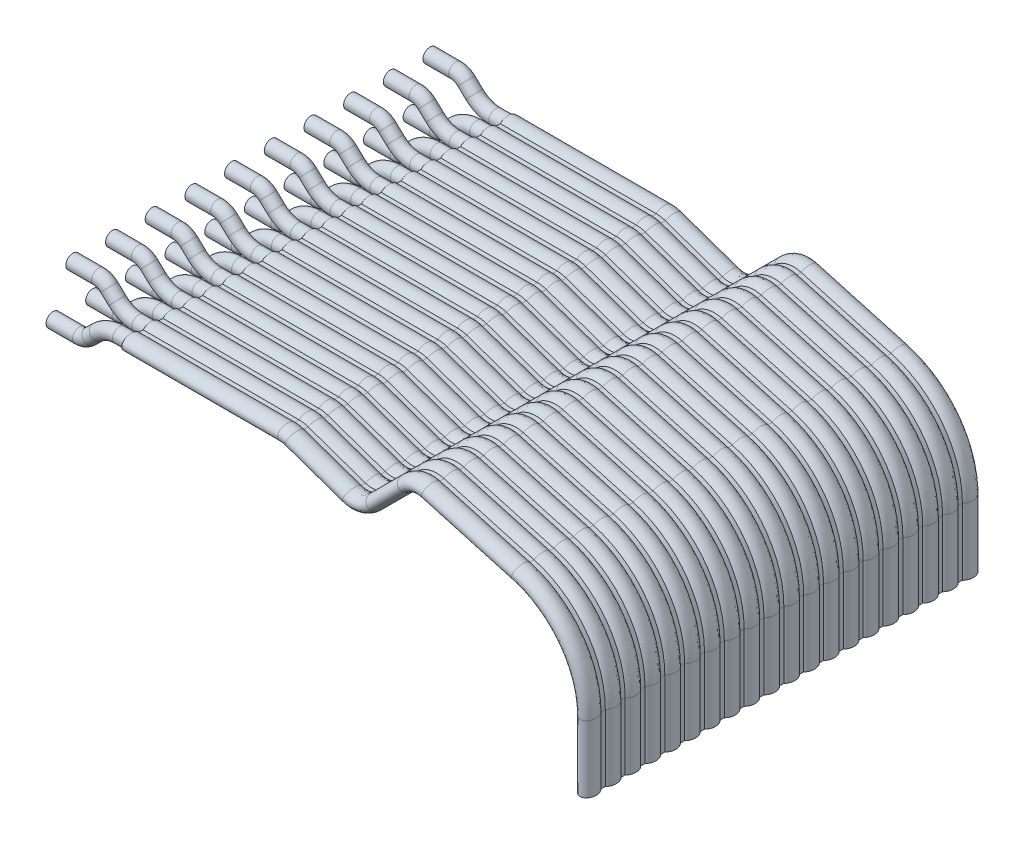
from build123d import *

# Parameters (mm, degrees)
SKETCH5_R           = 0.45
SKETCH8_R           = 0.45
LPATTERN1_COUNT     = 5
LPATTERN1_PITCH     = 2.54
LPATTERN1_COL_COUNT = 6
LPATTERN1_COL_PITCH = 2.54
LPATTERN2_COUNT     = 5
LPATTERN2_PITCH     = 2.54
LPATTERN2_COL_COUNT = 6
LPATTERN2_COL_PITCH = 2.54


with BuildPart() as part:
    # Main: sweep along a path in Sketch2
    with BuildLine(Plane.XY) as main_path:
        Line((0, 0), (9.982821531, 0))
        ThreePointArc((9.982821531, 0), (10.233848475, -0.021154006), (10.477795117, -0.084019368))
        Line((10.477795117, -0.084019368), (14.146689368, -1.366526843))
        ThreePointArc((14.146689368, -1.366526843), (14.97567416, -1.41288561), (15.702323126, -1.011206384))
        Line((15.702323126, -1.011206384), (17.724735893, 1.011206384))
        ThreePointArc((17.724735893, 1.011206384), (18.405878021, 1.401740911), (19.191003339, 1.394666269))
        Line((19.191003339, 1.394666269), (24.952376642, -0.223519771))
        ThreePointArc((24.952376642, -0.223519771), (28.111922797, -2.376091514), (29.329947548, -6))
        Line((29.329947548, -6), (29.329947548, -10.274872025))
    # Sketch3 → Main (sweep)
    with BuildSketch(Plane(origin=(0, 0, 0), x_dir=(0, 0, -1), z_dir=(1, 0, 0))):
        with BuildLine():
            Line((11.566112348, 0.25), (11.293887652, 0.25))
            add(Edge.make_bspline(
                [(11.293887652, 0.25), (10.795, 0.81), (10.296112348, 0.25)],
                knots=[3.730623624, 3.730623624, 3.730623624, 5.694154337, 5.694154337, 5.694154337], degree=2, weights=[1, 0.555555556, 1]))
            Line((10.296112348, 0.25), (10.023887652, 0.25))
            add(Edge.make_bspline(
                [(10.023887652, 0.25), (9.525, 0.81), (9.026112348, 0.25)],
                knots=[3.730623624, 3.730623624, 3.730623624, 5.694154337, 5.694154337, 5.694154337], degree=2, weights=[1, 0.555555556, 1]))
            Line((9.026112348, 0.25), (8.753887652, 0.25))
            add(Edge.make_bspline(
                [(8.753887652, 0.25), (8.255, 0.81), (7.756112348, 0.25)],
                knots=[3.730623624, 3.730623624, 3.730623624, 5.694154337, 5.694154337, 5.694154337], degree=2, weights=[1, 0.555555556, 1]))
            Line((7.756112348, 0.25), (7.483887652, 0.25))
            add(Edge.make_bspline(
                [(7.483887652, 0.25), (6.985, 0.81), (6.486112348, 0.25)],
                knots=[3.730623624, 3.730623624, 3.730623624, 5.694154337, 5.694154337, 5.694154337], degree=2, weights=[1, 0.555555556, 1]))
            Line((6.486112348, 0.25), (6.213887652, 0.25))
            add(Edge.make_bspline(
                [(6.213887652, 0.25), (5.715, 0.81), (5.216112348, 0.25)],
                knots=[3.730623624, 3.730623624, 3.730623624, 5.694154337, 5.694154337, 5.694154337], degree=2, weights=[1, 0.555555556, 1]))
            Line((5.216112348, 0.25), (4.943887652, 0.25))
            add(Edge.make_bspline(
                [(4.943887652, 0.25), (4.445, 0.81), (3.946112348, 0.25)],
                knots=[3.730623624, 3.730623624, 3.730623624, 5.694154337, 5.694154337, 5.694154337], degree=2, weights=[1, 0.555555556, 1]))
            Line((3.946112348, 0.25), (3.673887652, 0.25))
            add(Edge.make_bspline(
                [(3.673887652, 0.25), (3.175, 0.81), (2.676112348, 0.25)],
                knots=[0.58903097, 0.58903097, 0.58903097, 2.552561683, 2.552561683, 2.552561683], degree=2, weights=[1, 0.555555556, 1]))
            Line((2.676112348, 0.25), (2.403887652, 0.25))
            add(Edge.make_bspline(
                [(2.403887652, 0.25), (1.905, 0.81), (1.406112348, 0.25)],
                knots=[0.58903097, 0.58903097, 0.58903097, 2.552561683, 2.552561683, 2.552561683], degree=2, weights=[1, 0.555555556, 1]))
            Line((1.406112348, 0.25), (1.133887652, 0.25))
            add(Edge.make_bspline(
                [(1.133887652, 0.25), (0.635, 0.81), (0.136112348, 0.25)],
                knots=[3.730623624, 3.730623624, 3.730623624, 5.694154337, 5.694154337, 5.694154337], degree=2, weights=[1, 0.555555556, 1]))
            Line((0.136112348, 0.25), (-0.136112348, 0.25))
            add(Edge.make_bspline(
                [(-0.136112348, 0.25), (-0.635, 0.81), (-1.133887652, 0.25)],
                knots=[0.58903097, 0.58903097, 0.58903097, 2.552561683, 2.552561683, 2.552561683], degree=2, weights=[1, 0.555555556, 1]))
            Line((-1.133887652, 0.25), (-1.406112348, 0.25))
            add(Edge.make_bspline(
                [(-1.406112348, 0.25), (-1.905, 0.81), (-2.403887652, 0.25)],
                knots=[0.58903097, 0.58903097, 0.58903097, 2.552561683, 2.552561683, 2.552561683], degree=2, weights=[1, 0.555555556, 1]))
            Line((-2.403887652, 0.25), (-2.676112348, 0.25))
            add(Edge.make_bspline(
                [(-2.676112348, 0.25), (-3.175, 0.81), (-3.673887652, 0.25)],
                knots=[3.730623624, 3.730623624, 3.730623624, 5.694154337, 5.694154337, 5.694154337], degree=2, weights=[1, 0.555555556, 1]))
            Line((-3.673887652, 0.25), (-3.946112348, 0.25))
            add(Edge.make_bspline(
                [(-3.946112348, 0.25), (-4.445, 0.81), (-4.943887652, 0.25)],
                knots=[3.730623624, 3.730623624, 3.730623624, 5.694154337, 5.694154337, 5.694154337], degree=2, weights=[1, 0.555555556, 1]))
            Line((-4.943887652, 0.25), (-5.216112348, 0.25))
            add(Edge.make_bspline(
                [(-5.216112348, 0.25), (-5.715, 0.81), (-6.213887652, 0.25)],
                knots=[3.730623624, 3.730623624, 3.730623624, 5.694154337, 5.694154337, 5.694154337], degree=2, weights=[1, 0.555555556, 1]))
            Line((-6.213887652, 0.25), (-6.486112348, 0.25))
            add(Edge.make_bspline(
                [(-6.486112348, 0.25), (-6.985, 0.81), (-7.483887652, 0.25)],
                knots=[3.730623624, 3.730623624, 3.730623624, 5.694154337, 5.694154337, 5.694154337], degree=2, weights=[1, 0.555555556, 1]))
            Line((-7.483887652, 0.25), (-7.756112348, 0.25))
            add(Edge.make_bspline(
                [(-7.756112348, 0.25), (-8.255, 0.81), (-8.753887652, 0.25)],
                knots=[3.730623624, 3.730623624, 3.730623624, 5.694154337, 5.694154337, 5.694154337], degree=2, weights=[1, 0.555555556, 1]))
            Line((-8.753887652, 0.25), (-9.026112348, 0.25))
            add(Edge.make_bspline(
                [(-9.026112348, 0.25), (-9.525, 0.81), (-10.023887652, 0.25)],
                knots=[3.730623624, 3.730623624, 3.730623624, 5.694154337, 5.694154337, 5.694154337], degree=2, weights=[1, 0.555555556, 1]))
            Line((-10.023887652, 0.25), (-10.296112348, 0.25))
            add(Edge.make_bspline(
                [(-10.296112348, 0.25), (-10.795, 0.81), (-11.293887652, 0.25)],
                knots=[3.730623624, 3.730623624, 3.730623624, 5.694154337, 5.694154337, 5.694154337], degree=2, weights=[1, 0.555555556, 1]))
            Line((-11.293887652, 0.25), (-11.566112348, 0.25))
            add(Edge.make_bspline(
                [(-11.566112348, 0.25), (-12.665, 1.48349833), (-12.665, 0), (-12.665, -1.48349833), (-11.566112348, -0.25)],
                knots=[3.730623624, 3.730623624, 3.730623624, 6.283185307, 6.283185307, 8.835746991, 8.835746991, 8.835746991], degree=2, weights=[1, 0.290276231, 1, 0.290276231, 1]))
            Line((-11.566112348, -0.25), (-11.293887652, -0.25))
            add(Edge.make_bspline(
                [(-11.293887652, -0.25), (-10.795, -0.81), (-10.296112348, -0.25)],
                knots=[0.58903097, 0.58903097, 0.58903097, 2.552561683, 2.552561683, 2.552561683], degree=2, weights=[1, 0.555555556, 1]))
            Line((-10.296112348, -0.25), (-10.023887652, -0.25))
            add(Edge.make_bspline(
                [(-10.023887652, -0.25), (-9.525, -0.81), (-9.026112348, -0.25)],
                knots=[0.58903097, 0.58903097, 0.58903097, 2.552561683, 2.552561683, 2.552561683], degree=2, weights=[1, 0.555555556, 1]))
            Line((-9.026112348, -0.25), (-8.753887652, -0.25))
            add(Edge.make_bspline(
                [(-8.753887652, -0.25), (-8.255, -0.81), (-7.756112348, -0.25)],
                knots=[0.58903097, 0.58903097, 0.58903097, 2.552561683, 2.552561683, 2.552561683], degree=2, weights=[1, 0.555555556, 1]))
            Line((-7.756112348, -0.25), (-7.483887652, -0.25))
            add(Edge.make_bspline(
                [(-7.483887652, -0.25), (-6.985, -0.81), (-6.486112348, -0.25)],
                knots=[0.58903097, 0.58903097, 0.58903097, 2.552561683, 2.552561683, 2.552561683], degree=2, weights=[1, 0.555555556, 1]))
            Line((-6.486112348, -0.25), (-6.213887652, -0.25))
            add(Edge.make_bspline(
                [(-6.213887652, -0.25), (-5.715, -0.81), (-5.216112348, -0.25)],
                knots=[0.58903097, 0.58903097, 0.58903097, 2.552561683, 2.552561683, 2.552561683], degree=2, weights=[1, 0.555555556, 1]))
            Line((-5.216112348, -0.25), (-4.943887652, -0.25))
            add(Edge.make_bspline(
                [(-4.943887652, -0.25), (-4.445, -0.81), (-3.946112348, -0.25)],
                knots=[0.58903097, 0.58903097, 0.58903097, 2.552561683, 2.552561683, 2.552561683], degree=2, weights=[1, 0.555555556, 1]))
            Line((-3.946112348, -0.25), (-3.673887652, -0.25))
            add(Edge.make_bspline(
                [(-3.673887652, -0.25), (-3.175, -0.81), (-2.676112348, -0.25)],
                knots=[0.58903097, 0.58903097, 0.58903097, 2.552561683, 2.552561683, 2.552561683], degree=2, weights=[1, 0.555555556, 1]))
            Line((-2.676112348, -0.25), (-2.403887652, -0.25))
            add(Edge.make_bspline(
                [(-2.403887652, -0.25), (-1.905, -0.81), (-1.406112348, -0.25)],
                knots=[3.730623624, 3.730623624, 3.730623624, 5.694154337, 5.694154337, 5.694154337], degree=2, weights=[1, 0.555555556, 1]))
            Line((-1.406112348, -0.25), (-1.133887652, -0.25))
            add(Edge.make_bspline(
                [(-1.133887652, -0.25), (-0.635, -0.81), (-0.136112348, -0.25)],
                knots=[3.730623624, 3.730623624, 3.730623624, 5.694154337, 5.694154337, 5.694154337], degree=2, weights=[1, 0.555555556, 1]))
            Line((-0.136112348, -0.25), (0.136112348, -0.25))
            add(Edge.make_bspline(
                [(0.136112348, -0.25), (0.635, -0.81), (1.133887652, -0.25)],
                knots=[0.58903097, 0.58903097, 0.58903097, 2.552561683, 2.552561683, 2.552561683], degree=2, weights=[1, 0.555555556, 1]))
            Line((1.133887652, -0.25), (1.406112348, -0.25))
            add(Edge.make_bspline(
                [(1.406112348, -0.25), (1.905, -0.81), (2.403887652, -0.25)],
                knots=[3.730623624, 3.730623624, 3.730623624, 5.694154337, 5.694154337, 5.694154337], degree=2, weights=[1, 0.555555556, 1]))
            Line((2.403887652, -0.25), (2.676112348, -0.25))
            add(Edge.make_bspline(
                [(2.676112348, -0.25), (3.175, -0.81), (3.673887652, -0.25)],
                knots=[3.730623624, 3.730623624, 3.730623624, 5.694154337, 5.694154337, 5.694154337], degree=2, weights=[1, 0.555555556, 1]))
            Line((3.673887652, -0.25), (3.946112348, -0.25))
            add(Edge.make_bspline(
                [(3.946112348, -0.25), (4.445, -0.81), (4.943887652, -0.25)],
                knots=[0.58903097, 0.58903097, 0.58903097, 2.552561683, 2.552561683, 2.552561683], degree=2, weights=[1, 0.555555556, 1]))
            Line((4.943887652, -0.25), (5.216112348, -0.25))
            add(Edge.make_bspline(
                [(5.216112348, -0.25), (5.715, -0.81), (6.213887652, -0.25)],
                knots=[0.58903097, 0.58903097, 0.58903097, 2.552561683, 2.552561683, 2.552561683], degree=2, weights=[1, 0.555555556, 1]))
            Line((6.213887652, -0.25), (6.486112348, -0.25))
            add(Edge.make_bspline(
                [(6.486112348, -0.25), (6.985, -0.81), (7.483887652, -0.25)],
                knots=[0.58903097, 0.58903097, 0.58903097, 2.552561683, 2.552561683, 2.552561683], degree=2, weights=[1, 0.555555556, 1]))
            Line((7.483887652, -0.25), (7.756112348, -0.25))
            add(Edge.make_bspline(
                [(7.756112348, -0.25), (8.255, -0.81), (8.753887652, -0.25)],
                knots=[0.58903097, 0.58903097, 0.58903097, 2.552561683, 2.552561683, 2.552561683], degree=2, weights=[1, 0.555555556, 1]))
            Line((8.753887652, -0.25), (9.026112348, -0.25))
            add(Edge.make_bspline(
                [(9.026112348, -0.25), (9.525, -0.81), (10.023887652, -0.25)],
                knots=[0.58903097, 0.58903097, 0.58903097, 2.552561683, 2.552561683, 2.552561683], degree=2, weights=[1, 0.555555556, 1]))
            Line((10.023887652, -0.25), (10.296112348, -0.25))
            add(Edge.make_bspline(
                [(10.296112348, -0.25), (10.795, -0.81), (11.293887652, -0.25)],
                knots=[0.58903097, 0.58903097, 0.58903097, 2.552561683, 2.552561683, 2.552561683], degree=2, weights=[1, 0.555555556, 1]))
            Line((11.293887652, -0.25), (11.566112348, -0.25))
            add(Edge.make_bspline(
                [(11.566112348, -0.25), (12.665, -1.48349833), (12.665, 0), (12.665, 1.48349833), (11.566112348, 0.25)],
                knots=[0.58903097, 0.58903097, 0.58903097, 3.141592654, 3.141592654, 5.694154337, 5.694154337, 5.694154337], degree=2, weights=[1, 0.290276231, 1, 0.290276231, 1]))
        make_face()
    sweep(path=main_path.line)

    # pinUp: sweep along a path in Sketch6
    with BuildLine(Plane.XY) as pinup_path:
        Line((0, 0), (-0.783312036, 0))
        ThreePointArc((-0.783312036, 0), (-1.522448077, 0.141592641), (-2.156927894, 0.546322086))
        Line((-2.156927894, 0.546322086), (-2.66545199, 1.026838957))
        ThreePointArc((-2.66545199, 1.026838957), (-2.982691898, 1.22920368), (-3.352259918, 1.3))
        Line((-3.352259918, 1.3), (-5, 1.3))
    # Sketch5 → pinUp (sweep)
    with BuildSketch(Plane.ZY):
        with Locations((0.635, 0)):
            Circle(SKETCH5_R)
    pinup = sweep(path=pinup_path.line)

    # pinDown: sweep along a path in Sketch7
    with BuildLine(Plane.XY) as pindown_path:
        Line((0, 0), (-0.740903347, 0))
        ThreePointArc((-0.740903347, 0), (-1.487710161, -0.144661868), (-2.126482506, -0.557720417))
        Line((-2.126482506, -0.557720417), (-2.608865845, -1.021139791))
        ThreePointArc((-2.608865845, -1.021139791), (-2.928252017, -1.227669066), (-3.301655424, -1.3))
        Line((-3.301655424, -1.3), (-5, -1.3))
    # Sketch8 → pinDown (sweep)
    with BuildSketch(Plane.ZY):
        with Locations((-0.635, 0)):
            Circle(SKETCH8_R)
    pindown = sweep(path=pindown_path.line)

    # LPattern1: pinDown ×5
    with Locations(*[(0, 0, -i * LPATTERN1_PITCH) for i in range(1, LPATTERN1_COUNT)]):
        add(pindown)

    # LPattern1 col: pinDown ×6
    with Locations(*[(0, 0, i * LPATTERN1_COL_PITCH) for i in range(1, LPATTERN1_COL_COUNT)]):
        add(pindown)

    # LPattern2: pinUp ×5
    with Locations(*[(0, 0, i * LPATTERN2_PITCH) for i in range(1, LPATTERN2_COUNT)]):
        add(pinup)

    # LPattern2 col: pinUp ×6
    with Locations(*[(0, 0, -i * LPATTERN2_COL_PITCH) for i in range(1, LPATTERN2_COL_COUNT)]):
        add(pinup)


solid = part.part
